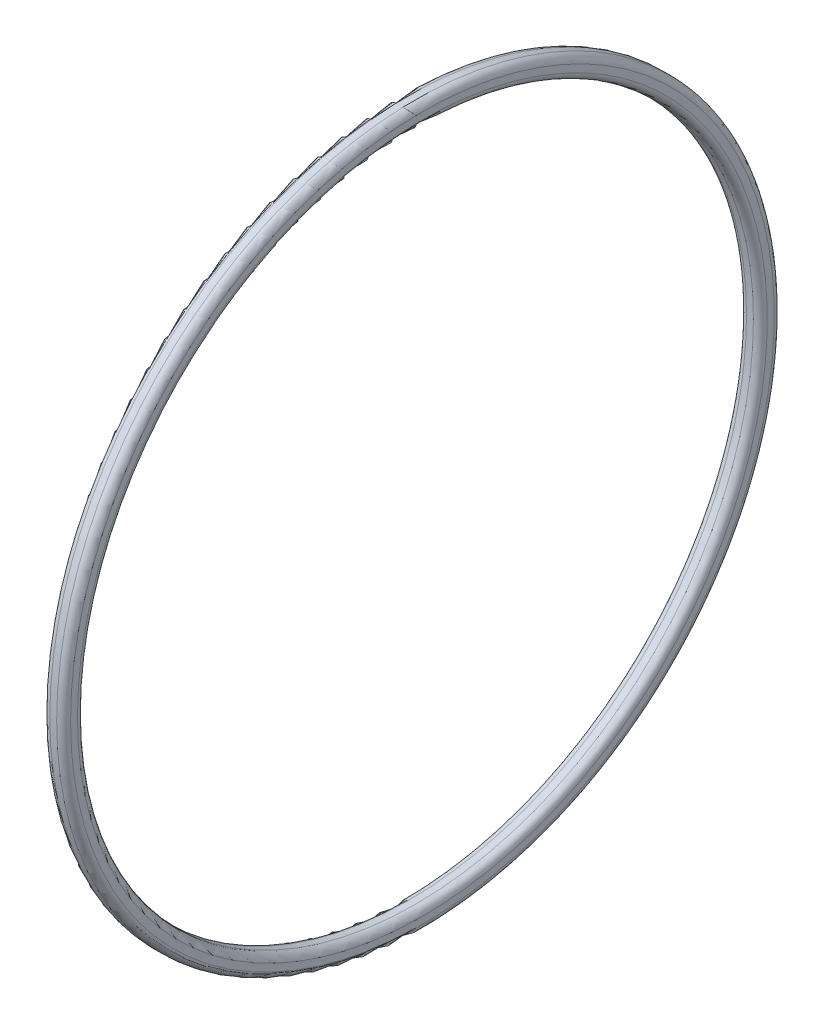
from build123d import *


with BuildPart() as part:
    # Schizzo1 → Rivoluzione1 (revolve)
    with BuildSketch(Plane.XY):
        with BuildLine():
            Line((-0.5, 51.75), (0.5, 51.75))
            ThreePointArc((0.5, 51.75), (1.207106781, 51.457106781), (1.5, 50.75))
            Line((1.5, 50.75), (1.5, 49.75))
            ThreePointArc((1.5, 49.75), (1.207106781, 49.042893219), (0.5, 48.75))
            Line((0.5, 48.75), (-0.5, 48.75))
            ThreePointArc((-0.5, 48.75), (-1.207106781, 49.042893219), (-1.5, 49.75))
            Line((-1.5, 49.75), (-1.5, 50.75))
            ThreePointArc((-1.5, 50.75), (-1.207106781, 51.457106781), (-0.5, 51.75))
        make_face()
    revolve(axis=Axis((0, 0, 0), (1, 0, 0)))


solid = part.part
